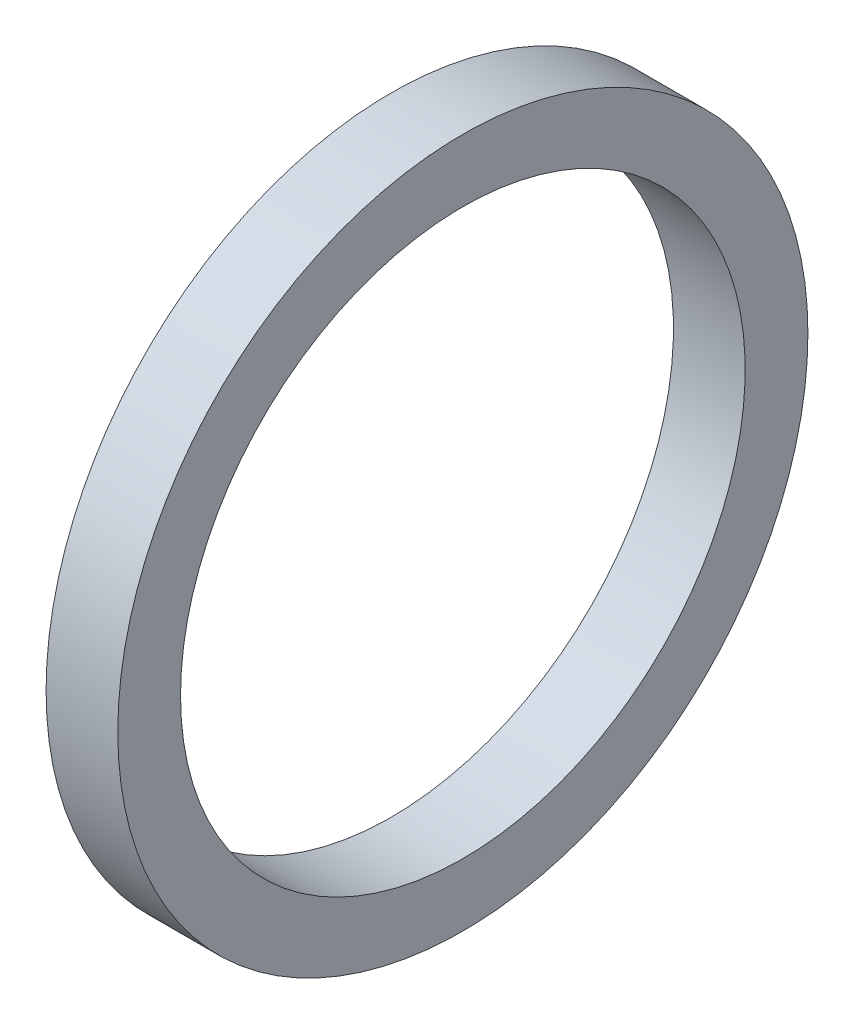
from build123d import *

# Parameters (mm, degrees)
SKETCH1_W = 2.032
SKETCH1_H = 1.778


with BuildPart() as part:
    # Sketch1 → Revolve1 (revolve)
    with BuildSketch(Plane.XY, mode=Mode.PRIVATE) as revolve1_sk:
        with Locations((1.016, -8.89)):
            Rectangle(SKETCH1_W, SKETCH1_H)
    revolve(revolve1_sk.sketch.rotate(Axis((-43.716580756, 0, 0), (1, 0, 0)), 270), axis=Axis((-43.716580756, 0, 0), (1, 0, 0)))  # turned: the seam where the file's is


solid = part.part
